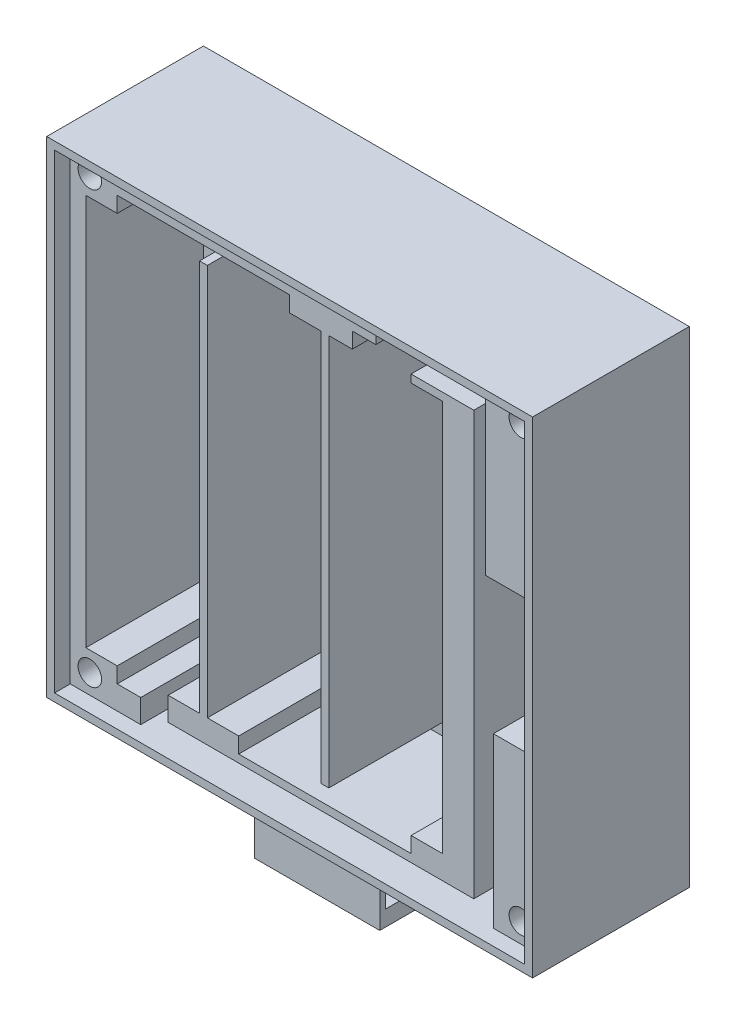
from build123d import *

# Parameters (mm, degrees)
CROQUIS1_W              = 62
CROQUIS1_H              = 62
SALIENTE_EXTRUIR1_DEPTH = 20
CORTAR_EXTRUIR1_DEPTH   = 17
CORTAR_EXTRUIR2_DEPTH   = 2
CORTAR_EXTRUIR3_START   = -18
CROQUIS4_R              = 1.5
CORTAR_EXTRUIR3_DEPTH   = 18
CROQUIS5_W              = 16
CROQUIS5_H              = 13
SALIENTE_EXTRUIR2_DEPTH = 8
CROQUIS6_W              = 11.961680629
CROQUIS6_H              = 9
CORTAR_EXTRUIR4_DEPTH   = 8
CROQUIS7_W              = 7
CROQUIS7_H              = 7
CORTAR_EXTRUIR5_DEPTH   = 1
CORTAR_EXTRUIR6_START   = -16
CROQUIS8_W              = 11.5
CROQUIS8_H              = 2.4
CORTAR_EXTRUIR6_DEPTH   = 16


with BuildPart() as part:
    # Croquis1 → Saliente-Extruir1 (new body)
    with BuildSketch(Plane.XY):
        with Locations((-78.537903487, 2.596858639)):
            Rectangle(CROQUIS1_W, CROQUIS1_H)
    extrude(amount=SALIENTE_EXTRUIR1_DEPTH)

    # Croquis2 → Cortar-Extruir1 (cut)
    with BuildSketch(Plane.XY.offset(20)):
        Polygon((-106.537903487, 27.596858639), (-106.537903487, -22.403141361), (-102.537903487, -22.403141361), (-102.537903487, -24.403141361), (-99.537903487, -24.403141361), (-99.537903487, -25.903141361), (-99.537903487, -27.403141361), (-54.537903487, -27.403141361), (-54.537903487, -25.903141361), (-54.537903487, -5.903141361), (-49.537903487, -5.903141361), (-49.537903487, 11.096858639), (-55.537903487, 11.096858639), (-55.537903487, 30.596858639), (-55.537903487, 31.596858639), (-69.537903487, 31.596858639), (-69.537903487, 29.596858639), (-72.537903487, 29.596858639), (-72.537903487, 27.596858639), (-75.537903487, 27.596858639), (-75.537903487, -22.403141361), (-76.537903487, -22.403141361), (-76.537903487, 27.596858639), (-80.537903487, 27.596858639), (-80.537903487, 29.596858639), (-102.537903487, 29.596858639), (-102.537903487, 27.596858639), align=None)
        Polygon((-92.037903487, 27.596858639), (-91.037903487, 27.596858639), (-91.037903487, -22.403141361), (-87.037903487, -22.403141361), (-87.037903487, -24.403141361), (-65.037903487, -24.403141361), (-65.037903487, -22.403141361), (-61.037903487, -22.403141361), (-61.037903487, 27.596858639), (-65.037903487, 27.596858639), (-65.037903487, 28.596858639), (-57.037903487, 28.596858639), (-57.037903487, -24.403141361), (-57.037903487, -25.403141361), (-96.037903487, -25.403141361), (-96.037903487, -24.403141361), (-96.037903487, -22.403141361), (-92.037903487, -22.403141361), align=None, mode=Mode.SUBTRACT)
    extrude(amount=-CORTAR_EXTRUIR1_DEPTH, mode=Mode.SUBTRACT)

    # Croquis3 → Cortar-Extruir2 (cut)
    with BuildSketch(Plane.XY.offset(20)):
        Polygon((-108.537903487, 27.596858639), (-108.537903487, 32.596858639), (-48.537903487, 32.596858639), (-48.537903487, -27.403141361), (-108.537903487, -27.403141361), align=None)
    extrude(amount=-CORTAR_EXTRUIR2_DEPTH, mode=Mode.SUBTRACT)

    # Croquis4 → Cortar-Extruir3 (cut)
    with BuildSketch(Plane.XY.offset(18).offset(CORTAR_EXTRUIR3_START)):
        with Locations((-106.037903487, 30.096858639)):
            Circle(CROQUIS4_R)
        with Locations((-51.037903487, 30.096858639)):
            Circle(CROQUIS4_R)
        with Locations((-51.037903487, -24.903141361)):
            Circle(CROQUIS4_R)
        with Locations((-106.037903487, -24.903141361)):
            Circle(CROQUIS4_R)
    extrude(amount=CORTAR_EXTRUIR3_DEPTH, mode=Mode.SUBTRACT)

    # Croquis5 → Saliente-Extruir2 (add)
    with BuildSketch(Plane.XZ.offset(28.403141361)):
        with Locations((-78.537903487, 10)):
            Rectangle(CROQUIS5_W, CROQUIS5_H)
    extrude(amount=SALIENTE_EXTRUIR2_DEPTH)

    # Croquis6 → Cortar-Extruir4 (cut)
    with BuildSketch(Plane.XZ.offset(36.403141361)):
        with Locations((-78.557063173, 10)):
            Rectangle(CROQUIS6_W, CROQUIS6_H)
    extrude(amount=-CORTAR_EXTRUIR4_DEPTH, mode=Mode.SUBTRACT)

    # Croquis7 → Cortar-Extruir5 (cut)
    with BuildSketch(Plane.XZ.offset(28.403141361)):
        with Locations((-80.037903487, 10)):
            Rectangle(CROQUIS7_W, CROQUIS7_H)
    extrude(amount=-CORTAR_EXTRUIR5_DEPTH, mode=Mode.SUBTRACT)

    # Croquis8 → Cortar-Extruir6 (cut)
    with BuildSketch(Plane(origin=(-70.537903487, 0, 0), x_dir=(0, 0, -1), z_dir=(1, 0, 0)).offset(CORTAR_EXTRUIR6_START)):
        with Locations((-10, -33.203141361)):
            Rectangle(CROQUIS8_W, CROQUIS8_H)
    extrude(amount=CORTAR_EXTRUIR6_DEPTH, mode=Mode.SUBTRACT)


solid = part.part
